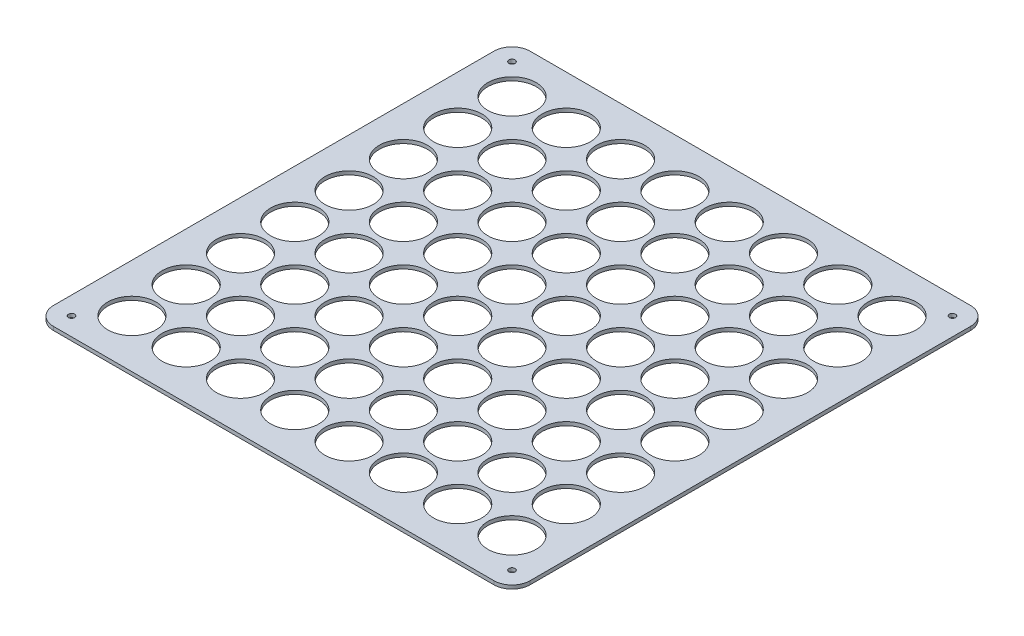
from build123d import *

# Parameters (mm, degrees)
SKETCH1_W            = 395
SKETCH1_H            = 395
SKETCH1_R            = 2.55
BOSS_EXTRUDE1_DEPTH  = 3
FILLET1_R            = 15
SKETCH2_R            = 20
CUT_EXTRUDE1_DEPTH   = 4
LPATTERN1_COUNT      = 8
LPATTERN1_PITCH      = 45
LPATTERN1_COUNT_DIR2 = 8
LPATTERN1_PITCH_DIR2 = 45


with BuildPart() as part:
    # Sketch1 → Boss-Extrude1 (new body)
    with BuildSketch(Plane(origin=(0, 0, 0), x_dir=(1, 0, 0), z_dir=(0, 1, 0))):
        Rectangle(SKETCH1_W, SKETCH1_H)
        with Locations((-182.5, 182.5)):
            Circle(SKETCH1_R, mode=Mode.SUBTRACT)
        with Locations((182.5, 182.5)):
            Circle(SKETCH1_R, mode=Mode.SUBTRACT)
        with Locations((182.5, -182.5)):
            Circle(SKETCH1_R, mode=Mode.SUBTRACT)
        with Locations((-182.5, -182.5)):
            Circle(SKETCH1_R, mode=Mode.SUBTRACT)
    extrude(amount=BOSS_EXTRUDE1_DEPTH)

    # Fillet1
    fillet1_edges = [part.edges().sort_by_distance(p)[0] for p in [
        (197.5, 1.5, 197.5),
        (-197.5, 1.5, 197.5),
        (-197.5, 1.5, -197.5),
        (197.5, 1.5, -197.5),
    ]]
    fillet(fillet1_edges, radius=FILLET1_R)

    # Sketch2 → Cut-Extrude1 (cut, through all)
    with BuildSketch(Plane(origin=(0, 3, 0), x_dir=(1, 0, 0), z_dir=(0, 1, 0))):
        with Locations((-157.5, -157.5)):
            Circle(SKETCH2_R)
    cut_extrude1 = extrude(amount=-CUT_EXTRUDE1_DEPTH, mode=Mode.SUBTRACT)

    # LPattern1: Cut-Extrude1 8 × 8
    with Locations(*[(j * LPATTERN1_PITCH_DIR2, 0, -i * LPATTERN1_PITCH) for i in range(LPATTERN1_COUNT) for j in range(LPATTERN1_COUNT_DIR2) if (i, j) != (0, 0)]):
        add(cut_extrude1, mode=Mode.SUBTRACT)


solid = part.part
